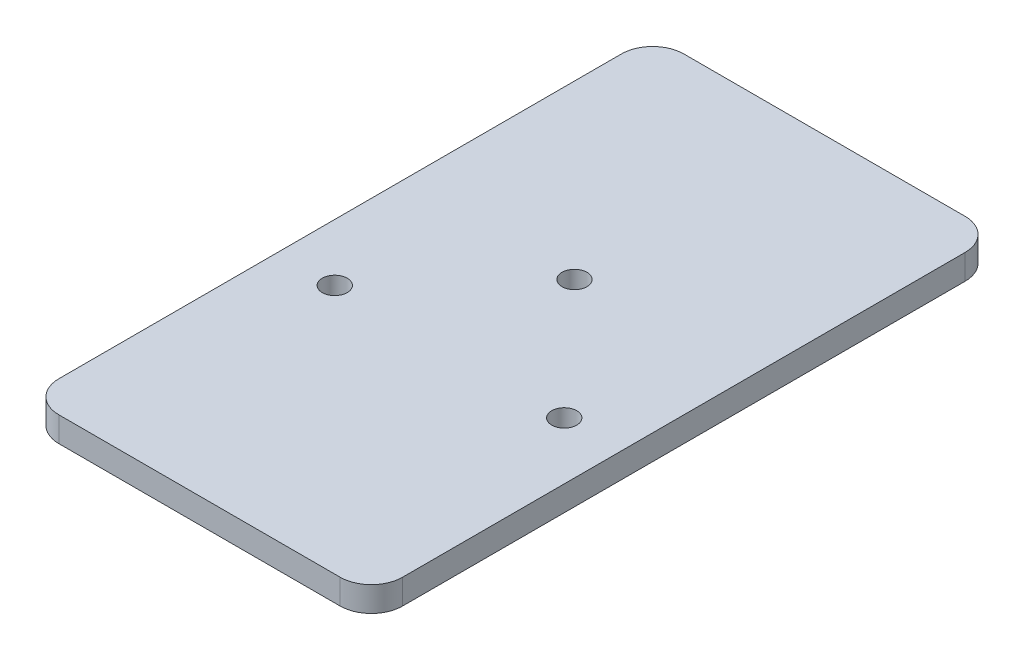
from build123d import *

# Parameters (mm, degrees)
SKETCH1_R           = 1
BOSS_EXTRUDE1_DEPTH = 2


with BuildPart() as part:
    # Sketch1 → Boss-Extrude1 (new body)
    with BuildSketch(Plane(origin=(0, 0, 0), x_dir=(1, 0, 0), z_dir=(0, 1, 0))):
        with BuildLine():
            Line((-11.25, -25), (11.25, -25))
            ThreePointArc((11.25, -25), (13.017766953, -24.267766953), (13.75, -22.5))
            Line((13.75, -22.5), (13.75, 22.5))
            ThreePointArc((13.75, 22.5), (13.017766953, 24.267766953), (11.25, 25))
            Line((11.25, 25), (-11.25, 25))
            ThreePointArc((-11.25, 25), (-13.017766953, 24.267766953), (-13.75, 22.5))
            Line((-13.75, 22.5), (-13.75, -22.5))
            ThreePointArc((-13.75, -22.5), (-13.017766953, -24.267766953), (-11.25, -25))
        make_face()
        with Locations((0, 5)):
            Circle(SKETCH1_R, mode=Mode.SUBTRACT)
        with Locations((-9.18, -5)):
            Circle(SKETCH1_R, mode=Mode.SUBTRACT)
        with Locations((9.18, -5)):
            Circle(SKETCH1_R, mode=Mode.SUBTRACT)
    extrude(amount=BOSS_EXTRUDE1_DEPTH)


solid = part.part
